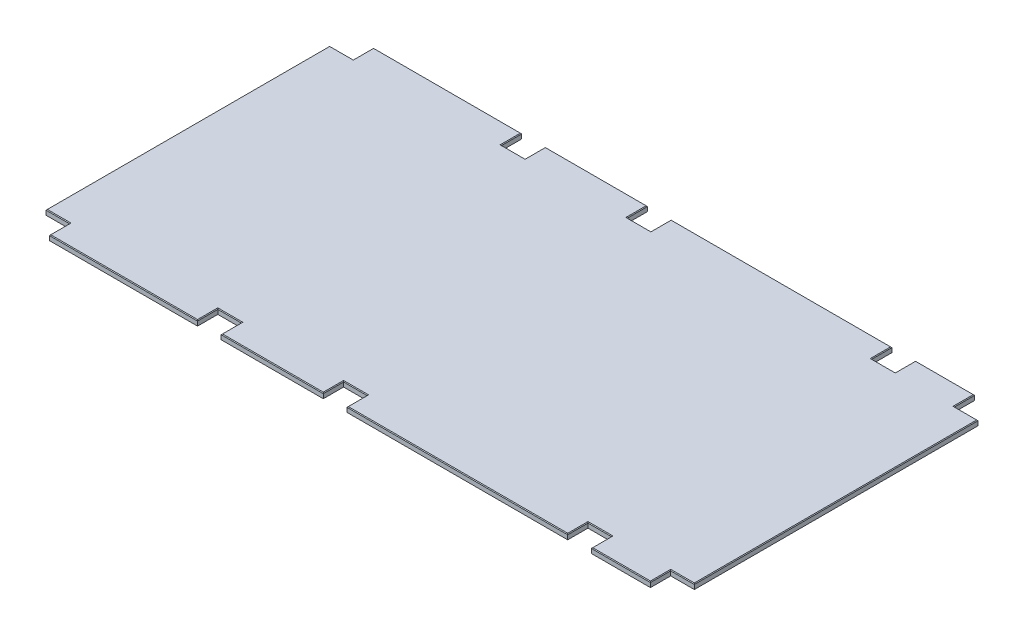
from build123d import *

# Parameters (mm, degrees)
SKETCH1_W           = 2438.4
SKETCH1_H           = 1219.2
BOSS_EXTRUDE1_DEPTH = 9.525
SKETCH2_W           = 88.9
SKETCH2_H           = 76.2
CUT_EXTRUDE1_DEPTH  = 20.05
CHAMFER1_SIZE       = 2.54


with BuildPart() as part:
    # Sketch1 → Boss-Extrude1 (new body, symmetric)
    with BuildSketch(Plane(origin=(0, 0, 0), x_dir=(1, 0, 0), z_dir=(0, 1, 0))):
        with Locations((1219.2, 609.6)):
            Rectangle(SKETCH1_W, SKETCH1_H)
    extrude(amount=BOSS_EXTRUDE1_DEPTH, both=True)

    # Sketch2 → Cut-Extrude1 (cut, through all)
    with BuildSketch(Plane(origin=(0, 9.525, 0), x_dir=(1, 0, 0), z_dir=(0, 1, 0))):
        with Locations((44.45, 1181.1)):
            Rectangle(SKETCH2_W, SKETCH2_H)
        with Locations((690.5625, 1181.1)):
            Rectangle(SKETCH2_W, SKETCH2_H)
        with Locations((1163.6375, 1181.1)):
            Rectangle(SKETCH2_W, SKETCH2_H)
        with Locations((2082.8, 1181.1)):
            Rectangle(SKETCH2_W, SKETCH2_H)
        with Locations((2393.95, 1181.1)):
            Rectangle(SKETCH2_W, SKETCH2_H)
        with Locations((1163.6375, 38.1)):
            Rectangle(SKETCH2_W, SKETCH2_H)
        with Locations((690.5625, 38.1)):
            Rectangle(SKETCH2_W, SKETCH2_H)
        with Locations((2393.95, 38.1)):
            Rectangle(SKETCH2_W, SKETCH2_H)
        with Locations((2082.8, 38.1)):
            Rectangle(SKETCH2_W, SKETCH2_H)
        with Locations((44.45, 38.1)):
            Rectangle(SKETCH2_W, SKETCH2_H)
    extrude(amount=-CUT_EXTRUDE1_DEPTH, mode=Mode.SUBTRACT)

    # Chamfer1
    chamfer1_edges = [part.edges().sort_by_distance(p)[0] for p in [
        (2038.35, 9.525, -1181.1),
        (2082.8, 9.525, -1143),
        (2127.25, 9.525, -1181.1),
        (1208.0875, 9.525, -1181.1),
        (1119.1875, 9.525, -1181.1),
        (1163.6375, 9.525, -1143),
        (646.1125, 9.525, -1181.1),
        (690.5625, 9.525, -1143),
        (735.0125, 9.525, -1181.1),
        (44.45, 9.525, -1143),
        (88.9, 9.525, -1181.1),
        (0, 9.525, -609.6),
        (367.50625, 9.525, 0),
        (927.1, 9.525, 0),
        (1623.21875, 9.525, 0),
        (2238.375, 9.525, 0),
        (2438.4, 9.525, -609.6),
        (2238.375, 9.525, -1219.2),
        (1623.21875, 9.525, -1219.2),
        (927.1, 9.525, -1219.2),
        (367.50625, 9.525, -1219.2),
        (88.9, 9.525, -38.1),
        (44.45, 9.525, -76.2),
        (2127.25, 9.525, -38.1),
        (2082.8, 9.525, -76.2),
        (2038.35, 9.525, -38.1),
        (2393.95, 9.525, -76.2),
        (2349.5, 9.525, -38.1),
        (735.0125, 9.525, -38.1),
        (690.5625, 9.525, -76.2),
        (646.1125, 9.525, -38.1),
        (1208.0875, 9.525, -38.1),
        (1163.6375, 9.525, -76.2),
        (1119.1875, 9.525, -38.1),
        (2349.5, 9.525, -1181.1),
        (2393.95, 9.525, -1143),
    ]]
    chamfer(chamfer1_edges, length=CHAMFER1_SIZE)


solid = part.part
